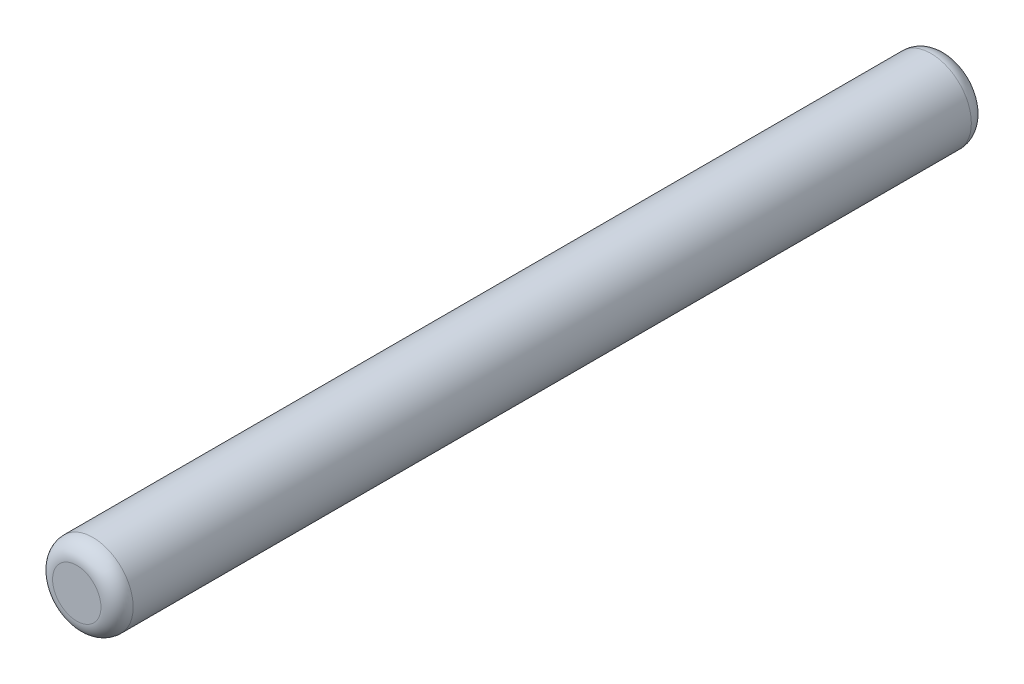
from build123d import *

# Parameters (mm, degrees)
SKETCH1_R           = 2.5
BOSS_EXTRUDE1_DEPTH = 54
FILLET1_R           = 1


with BuildPart() as part:
    # Sketch1 → Boss-Extrude1 (new body)
    with BuildSketch(Plane.XY):
        Circle(SKETCH1_R)
    extrude(amount=BOSS_EXTRUDE1_DEPTH)

    # Fillet1
    fillet1_edges = [part.edges().sort_by_distance(p)[0] for p in [
        (-2.5, 0, 0),
        (-2.5, 0, 54),
    ]]
    fillet(fillet1_edges, radius=FILLET1_R)


solid = part.part
